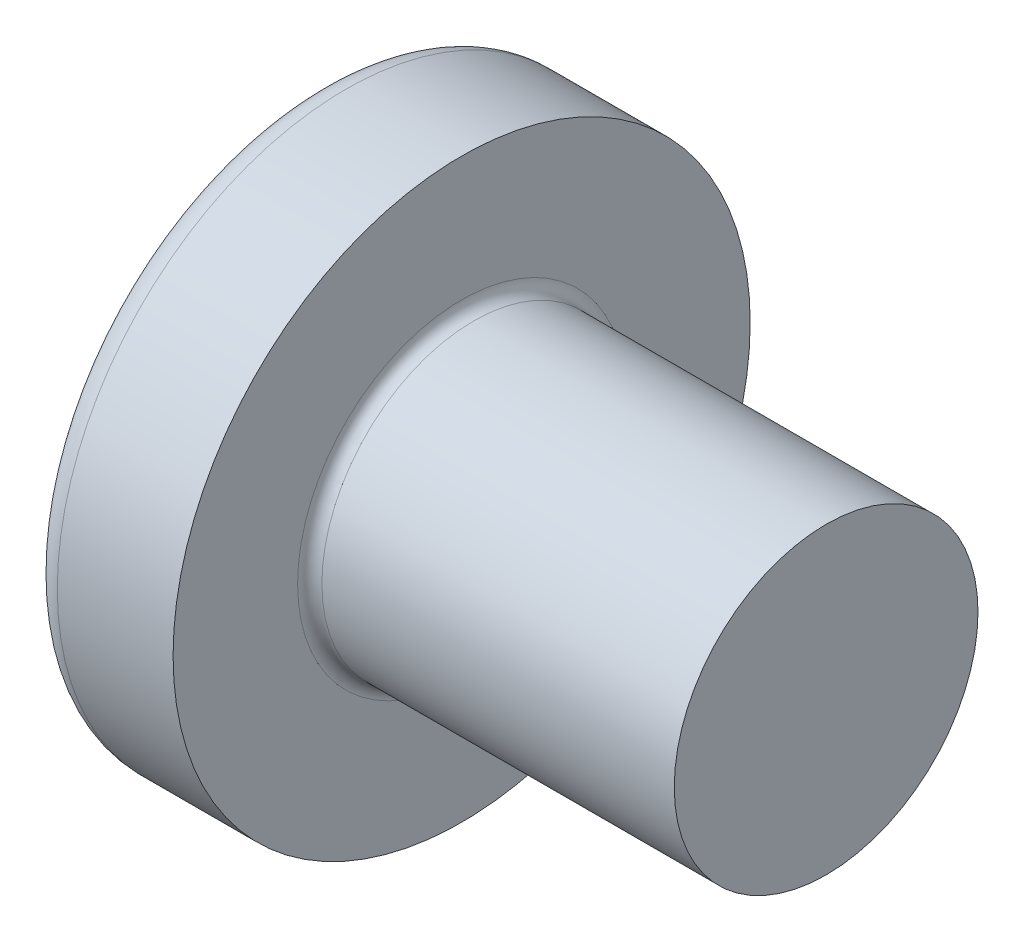
from build123d import *

# Parameters (mm, degrees)
FILLET1_R    = 0.2
SKETCH3_W    = 1.03
SKETCH3_H    = 4.7
SKETCH4_W    = 1.03
SKETCH4_H    = 1.967772882
RECPAT_COUNT = 2
RECPAT_ANGLE = 90


with BuildPart() as part:
    # BodySke → Base-Revolve (revolve)
    with BuildSketch(Plane.XY):
        with BuildLine():
            Line((3.7, 2.5), (3.7, 4.75))
            Line((3.7, 4.75), (1.79415598, 4.75))
            ThreePointArc((1.79415598, 4.75), (1.58538712, 4.698642149), (1.424271237, 4.556291391))
            ThreePointArc((1.424271237, 4.556291391), (0.364365445, 2.386856709), (0, 0))
            Line((0, 0), (9.7, 0))
            Line((9.7, 0), (9.7, 2.5))
            Line((9.7, 2.5), (3.7, 2.5))
        make_face()
    revolve(axis=Axis((-25.4, 0, 0), (1, 0, 0)))

    # Fillet1
    fillet1_edges = [part.edges().sort_by_distance(p)[0] for p in [
        (3.7, -2.5, 0),
    ]]
    fillet(fillet1_edges, radius=FILLET1_R)

    # Sketch3 → Recess section 0
    with BuildSketch(Plane(origin=(0, 0, 0), x_dir=(0, 0, -1), z_dir=(1, 0, 0))):
        Rectangle(SKETCH3_W, SKETCH3_H)
    # Sketch4 → Recess section 1
    with BuildSketch(Plane(origin=(2.74, 0, 0), x_dir=(0, 0, -1), z_dir=(1, 0, 0))):
        Rectangle(SKETCH4_W, SKETCH4_H)
    recess = loft(mode=Mode.SUBTRACT)

    # RecPat: Recess ×2 about axis
    recpat_axis = Axis((0, 0, 0), (1, 0, 0))
    for i in range(1, RECPAT_COUNT):
        add(recess.rotate(recpat_axis, i * RECPAT_ANGLE / (RECPAT_COUNT - 1)), mode=Mode.SUBTRACT)

    # RecCorSke → RecessCore (revolve, cut)
    with BuildSketch(Plane.XY):
        Polygon((0, 0), (0, 1.042599465), (2.74, 0.851), (3.016506661, 0), align=None)
    revolve(axis=Axis((-3.175, 0, 0), (1, 0, 0)), mode=Mode.SUBTRACT)


solid = part.part
